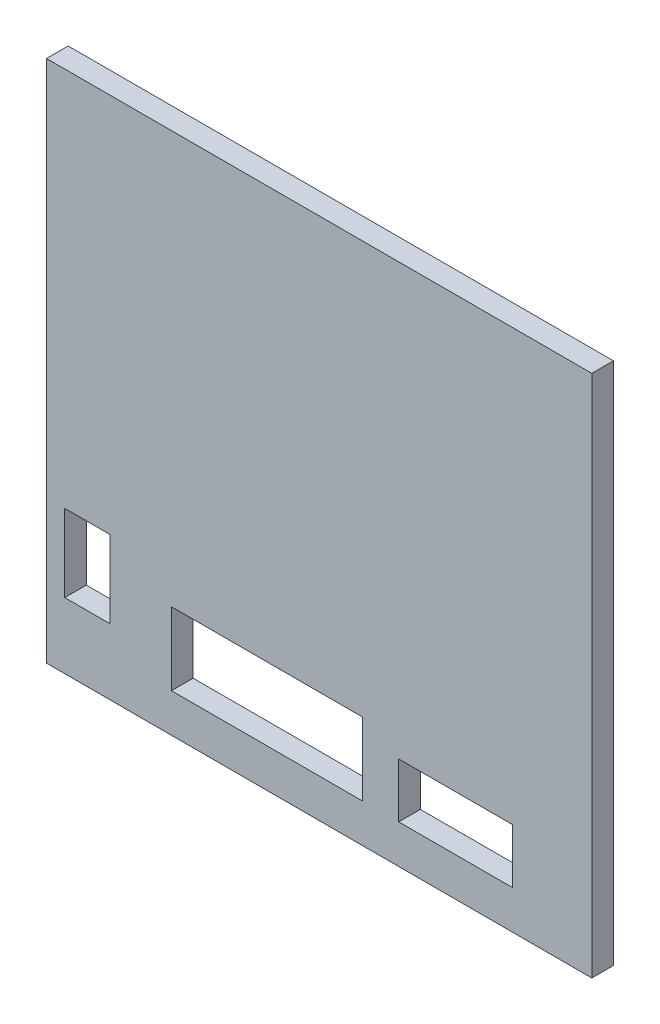
from build123d import *

# Parameters (mm, degrees)
SKETCH1_W           = 120
SKETCH1_H           = 115.2375
BOSS_EXTRUDE1_DEPTH = 4.7625
SKETCH2_W           = 25
SKETCH2_H           = 12
SKETCH2_W_2         = 42
SKETCH2_H_2         = 16
SKETCH2_W_3         = 10
SKETCH2_H_3         = 17
CUT_EXTRUDE1_DEPTH  = 5.7625


with BuildPart() as part:
    # Sketch1 → Boss-Extrude1 (new body)
    with BuildSketch(Plane.XY):
        Rectangle(SKETCH1_W, SKETCH1_H)
    extrude(amount=-BOSS_EXTRUDE1_DEPTH)

    # Sketch2 → Cut-Extrude1 (cut, through all)
    with BuildSketch(Plane.XY):
        with Locations((30, -43.11875)):
            Rectangle(SKETCH2_W, SKETCH2_H)
        with Locations((-11.5, -41.11875)):
            Rectangle(SKETCH2_W_2, SKETCH2_H_2)
        with Locations((-51, -34.61875)):
            Rectangle(SKETCH2_W_3, SKETCH2_H_3)
    extrude(amount=-CUT_EXTRUDE1_DEPTH, mode=Mode.SUBTRACT)


solid = part.part
